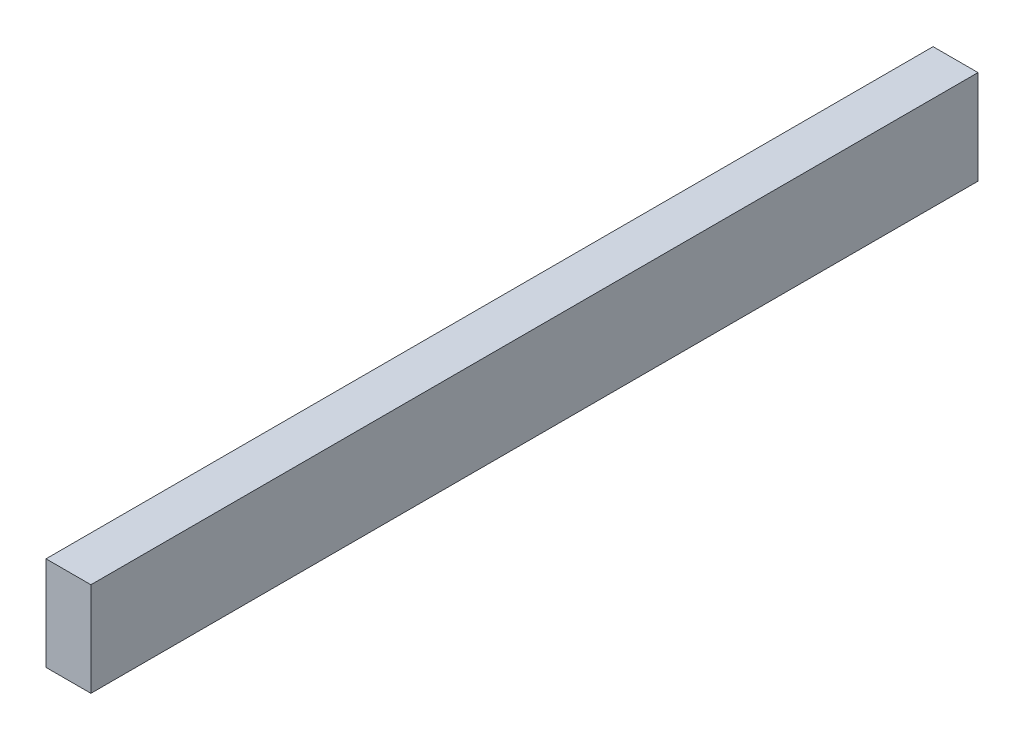
from build123d import *

# Parameters (mm, degrees)
SKETCH_1_W      = 7.59316048
SKETCH_1_H      = 31.812879904
EXTRUDE_1_DEPTH = 300


with BuildPart() as part:
    # 草图1 → 凸台-拉伸1 (new body)
    with BuildSketch(Plane.XY.offset(400)):
        with Locations((-3.79658024, -549.244775142)):
            Rectangle(SKETCH_1_W, SKETCH_1_H)
        with Locations((3.79658024, -549.244775142)):
            Rectangle(SKETCH_1_W, SKETCH_1_H)
    extrude(amount=EXTRUDE_1_DEPTH)


solid = part.part
